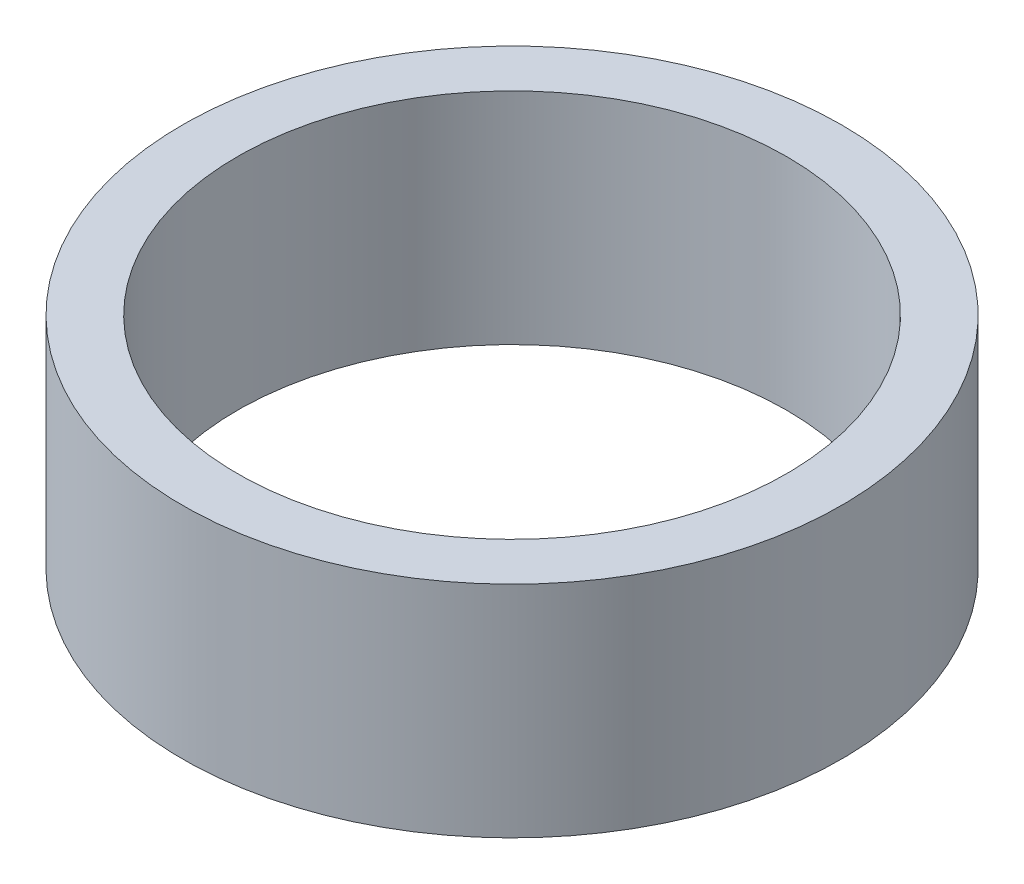
from build123d import *

# Parameters (mm, degrees)
SKETCH1_W = 0.25
SKETCH1_H = 1


with BuildPart() as part:
    # Sketch1 → Revolve1 (revolve)
    with BuildSketch(Plane.XY):
        with Locations((1.375, 0.5)):
            Rectangle(SKETCH1_W, SKETCH1_H)
    revolve(axis=Axis((0, 0, 0), (0, 1, 0)))


solid = part.part
